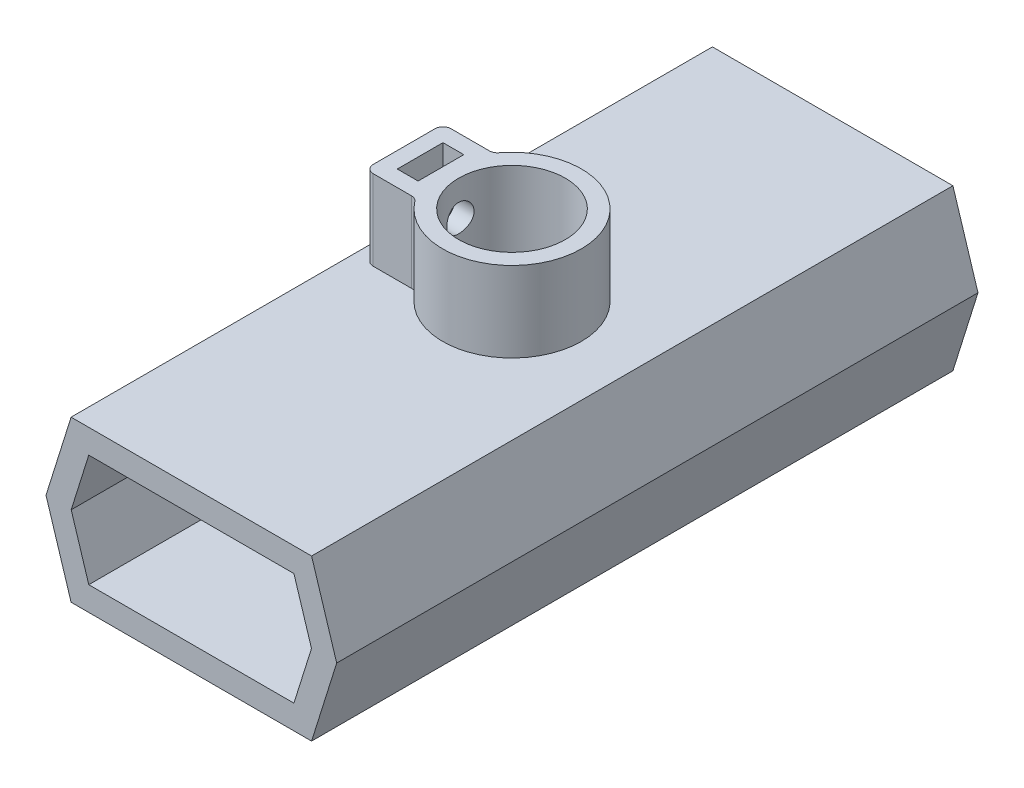
from build123d import *

# Parameters (mm, degrees)
EXTRUDE_1_DEPTH     = 40
CUT_EXTRUDE_3_DEPTH = 81
SKETCH_8_R          = 6.65
CUT_EXTRUDE_4_DEPTH = 21
SKETCH_9_R          = 8.65
SKETCH_9_R_2        = 6.65
EXTRUDE_2_DEPTH     = 10
SKETCH_10_W         = 2.6
SKETCH_10_H         = 5.7
EXTRUDE_3_DEPTH     = 10
SKETCH_11_R         = 1.7
CUT_EXTRUDE_5_DEPTH = 10
FILLET_1_R          = 1


with BuildPart() as part:
    # 草图1 → 凸台-拉伸1 (new body, symmetric)
    with BuildSketch(Plane.XY):
        Polygon((-15, 0), (15, 0), (18.130448736, -10), (15, -20), (-15, -20), (-18.130448736, -10), align=None)
    extrude(amount=EXTRUDE_1_DEPTH, both=True)

    # 草图7 → 切除-拉伸3 (cut, through all)
    with BuildSketch(Plane(origin=(0, 0, -40), x_dir=(-1, 0, 0), z_dir=(0, 0, -1))):
        Polygon((14.986888042, -10), (12.795573927, -3), (-12.795573927, -3), (-14.986888042, -10), (-12.795573927, -17), (12.795573927, -17), align=None)
    extrude(amount=-CUT_EXTRUDE_3_DEPTH, mode=Mode.SUBTRACT)

    # 草图8 → 切除-拉伸4 (cut, through all)
    with BuildSketch(Plane(origin=(0, 0, 0), x_dir=(1, 0, 0), z_dir=(0, 1, 0))):
        Circle(SKETCH_8_R)
    extrude(amount=-CUT_EXTRUDE_4_DEPTH, mode=Mode.SUBTRACT)

    # 草图9 → 凸台-拉伸2 (add)
    with BuildSketch(Plane(origin=(0, 0, 0), x_dir=(1, 0, 0), z_dir=(0, 1, 0))):
        Circle(SKETCH_9_R)
        Circle(SKETCH_9_R_2, mode=Mode.SUBTRACT)
    extrude(amount=EXTRUDE_2_DEPTH)

    # 草图10 → 凸台-拉伸3 (add)
    with BuildSketch(Plane(origin=(0, 0, 0), x_dir=(1, 0, 0), z_dir=(0, 1, 0))):
        with BuildLine():
            ThreePointArc((-7.158670401, -4.855505955), (-8.65, 0), (-7.158670401, 4.855505955))
            Line((-7.158670401, 4.855505955), (-13.461589548, 4.855505955))
            Line((-13.461589548, 4.855505955), (-13.461589548, -4.855505955))
            Line((-13.461589548, -4.855505955), (-7.158670401, -4.855505955))
        make_face()
        with Locations((-10.161589548, 0)):
            Rectangle(SKETCH_10_W, SKETCH_10_H, mode=Mode.SUBTRACT)
    extrude(amount=EXTRUDE_3_DEPTH)

    # 草图11 → 切除-拉伸5 (cut)
    with BuildSketch(Plane.ZY.offset(13.461589548)):
        with Locations((0, 5.684678401)):
            Circle(SKETCH_11_R)
    extrude(amount=-CUT_EXTRUDE_5_DEPTH, mode=Mode.SUBTRACT)

    # 圆角1
    fillet_1_edges = [part.edges().sort_by_distance(p)[0] for p in [
        (-13.461589548, 5, -4.855505955),
        (-13.461589548, 5, 4.855505955),
        (-7.158670401, 5, 4.855505955),
        (-7.158670401, 5, -4.855505955),
    ]]
    fillet(fillet_1_edges, radius=FILLET_1_R)


solid = part.part
